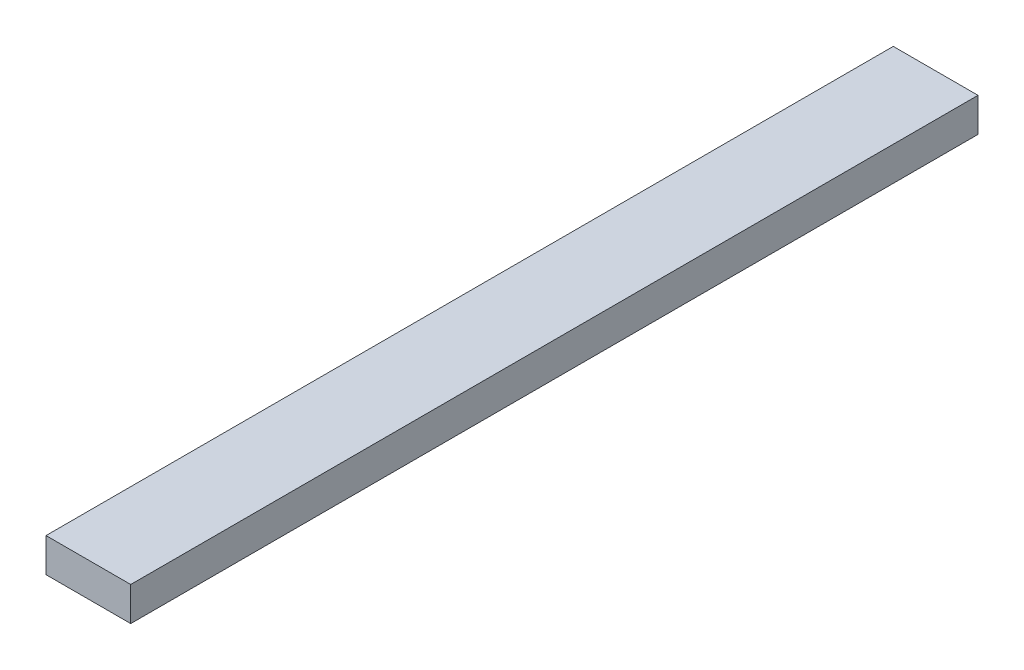
from build123d import *

# Parameters (mm, degrees)
SKETCH_1_W      = 50
SKETCH_1_H      = 20
EXTRUDE_1_DEPTH = 500


with BuildPart() as part:
    # ｽｹｯﾁ1 → ﾎﾞｽ - 押し出し1 (new body)
    with BuildSketch(Plane.XY):
        Rectangle(SKETCH_1_W, SKETCH_1_H)
    extrude(amount=EXTRUDE_1_DEPTH)


solid = part.part
